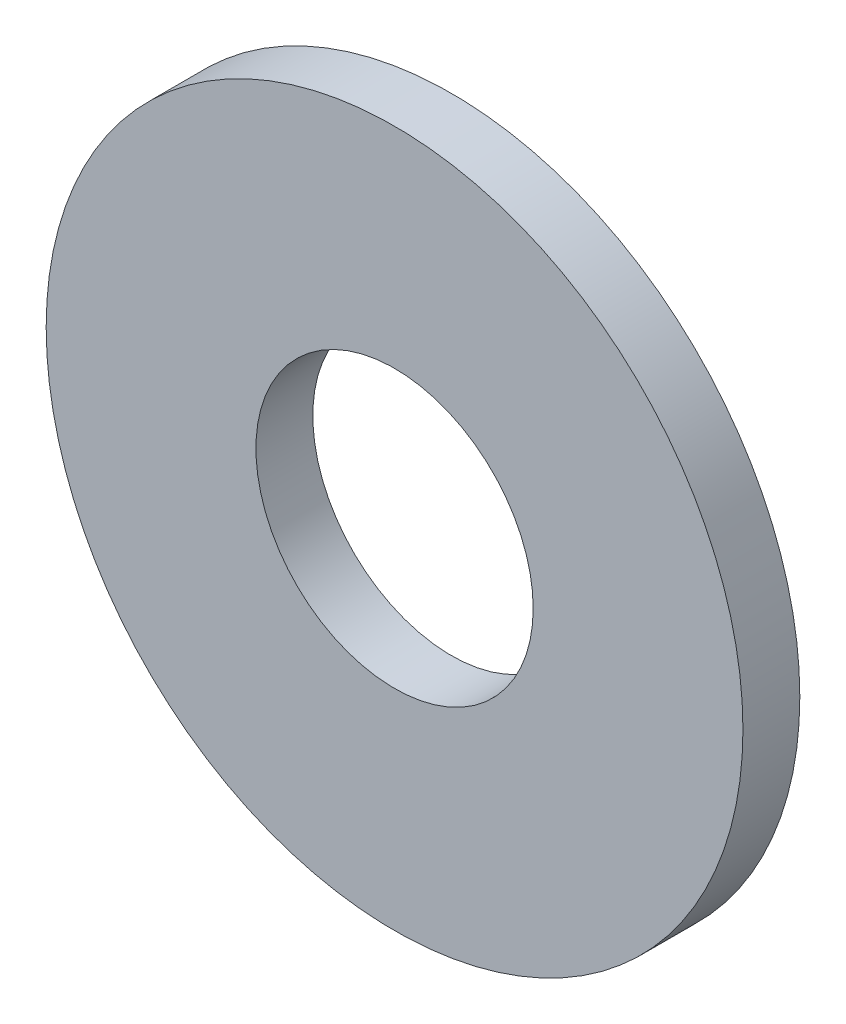
from build123d import *

# Parameters (mm, degrees)
SKETCH1_R           = 2.45
SKETCH1_R_2         = 0.975
BOSS_EXTRUDE1_DEPTH = 0.4


with BuildPart() as part:
    # Sketch1 → Boss-Extrude1 (new body)
    with BuildSketch(Plane.XY):
        Circle(SKETCH1_R)
        Circle(SKETCH1_R_2, mode=Mode.SUBTRACT)
    extrude(amount=BOSS_EXTRUDE1_DEPTH)


solid = part.part
